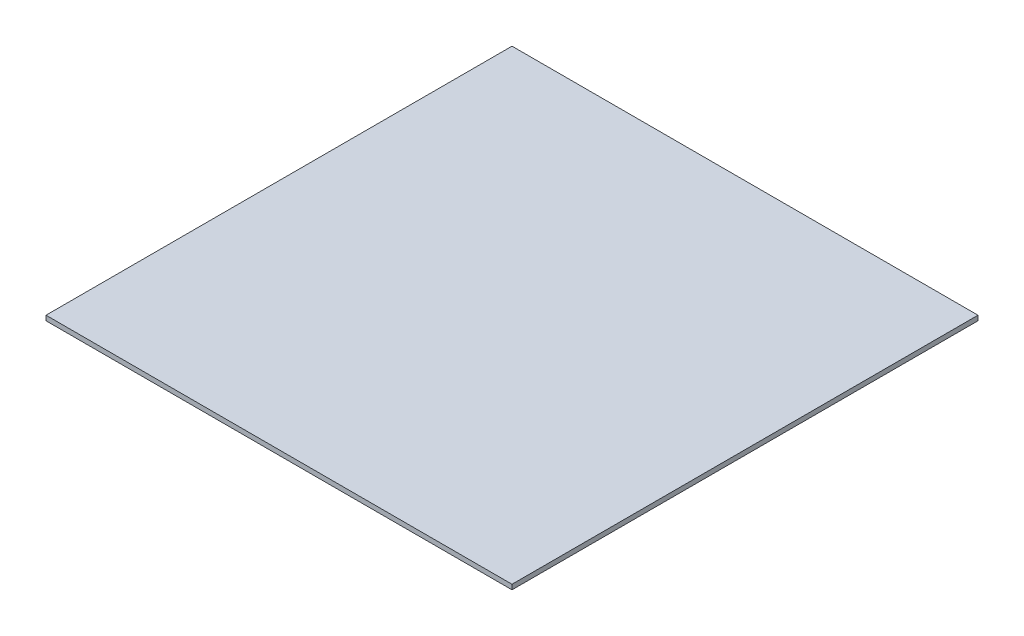
from build123d import *

# Parameters (mm, degrees)
SKETCH3_W                = 304.8
SKETCH3_H                = 304.8
BOSS_EXTRUDE1_DEPTH      = 1.5875
BOSS_EXTRUDE1_DEPTH_BACK = 1.5875


with BuildPart() as part:
    # Sketch3 → Boss-Extrude1 (new body, two sides)
    with BuildSketch(Plane(origin=(0, 0, 0), x_dir=(1, 0, 0), z_dir=(0, 1, 0))) as boss_extrude1_sk:
        Rectangle(SKETCH3_W, SKETCH3_H)
    extrude(amount=BOSS_EXTRUDE1_DEPTH)
    extrude(boss_extrude1_sk.sketch, amount=-BOSS_EXTRUDE1_DEPTH_BACK)


solid = part.part
